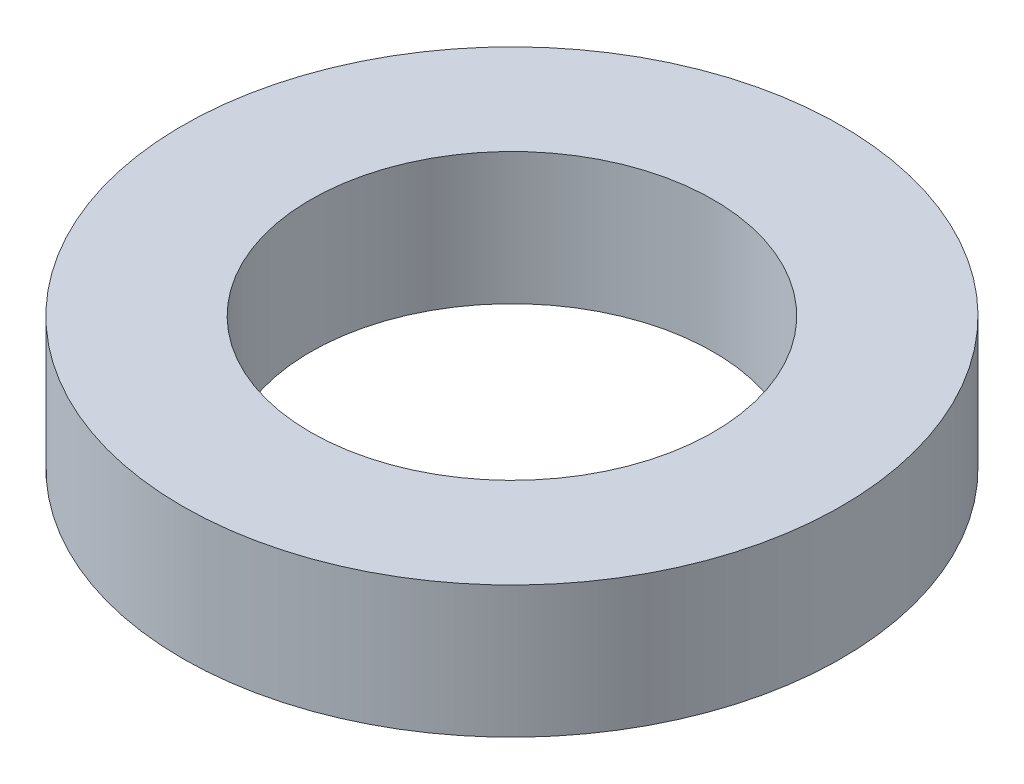
from build123d import *

# Parameters (mm, degrees)
SKETCH1_R           = 45
SKETCH1_R_2         = 27.5
BOSS_EXTRUDE1_DEPTH = 18


with BuildPart() as part:
    # Sketch1 → Boss-Extrude1 (new body)
    with BuildSketch(Plane(origin=(0, 0, 0), x_dir=(1, 0, 0), z_dir=(0, 1, 0))):
        Circle(SKETCH1_R)
        Circle(SKETCH1_R_2, mode=Mode.SUBTRACT)
    extrude(amount=BOSS_EXTRUDE1_DEPTH)


solid = part.part
